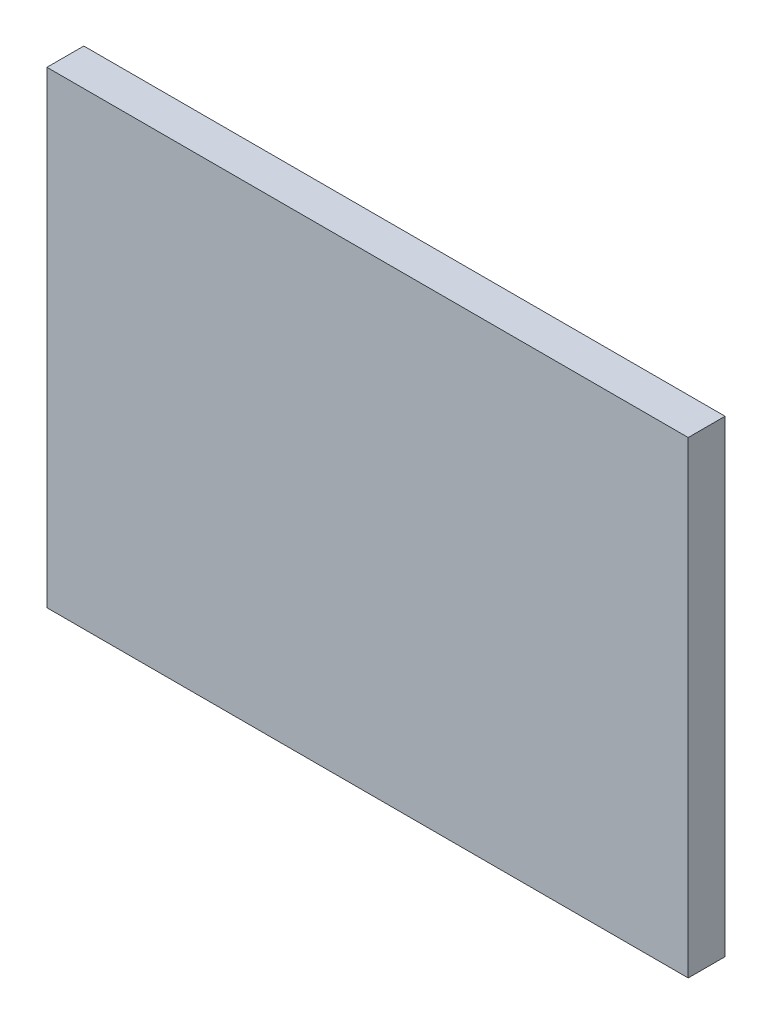
from build123d import *

# Parameters (mm, degrees)
SKETCH1_W           = 69.596
SKETCH1_H           = 50.8
BOSS_EXTRUDE1_DEPTH = 4


with BuildPart() as part:
    # Sketch1 → Boss-Extrude1 (new body)
    with BuildSketch(Plane.XY):
        Rectangle(SKETCH1_W, SKETCH1_H)
    extrude(amount=BOSS_EXTRUDE1_DEPTH)


solid = part.part
